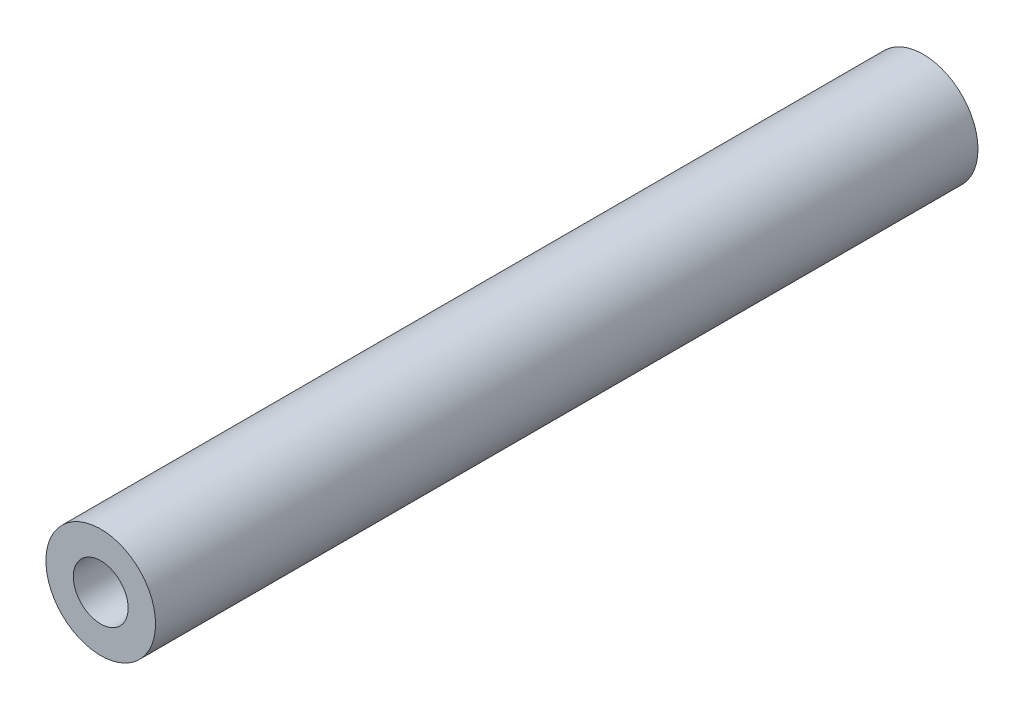
from build123d import *

# Parameters (mm, degrees)
ESQUISSE1_R        = 3
ESQUISSE1_R_2      = 1.5
BOSS_EXTRU_1_DEPTH = 45


with BuildPart() as part:
    # Esquisse1 → Boss.-Extru.1 (new body)
    with BuildSketch(Plane.XY):
        Circle(ESQUISSE1_R)
        Circle(ESQUISSE1_R_2, mode=Mode.SUBTRACT)
    extrude(amount=BOSS_EXTRU_1_DEPTH)


solid = part.part
